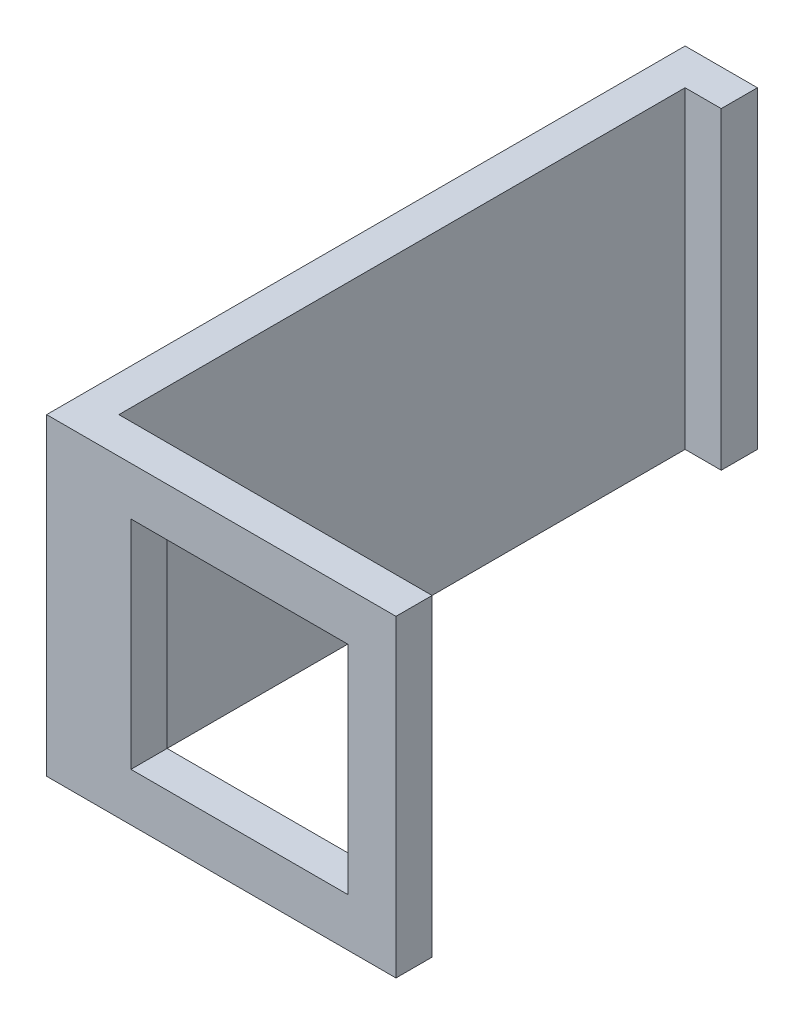
from build123d import *

# Parameters (mm, degrees)
SKETCH1_W           = 14.5
SKETCH1_H           = 13
SKETCH1_W_2         = 9
SKETCH1_H_2         = 9
BOSS_EXTRUDE1_DEPTH = 1.5
SKETCH2_W           = 1.5
SKETCH2_H           = 13
BOSS_EXTRUDE2_DEPTH = 25
SKETCH3_W           = 1.5
SKETCH3_H           = 13
BOSS_EXTRUDE3_DEPTH = 1.5


with BuildPart() as part:
    # Sketch1 → Boss-Extrude1 (new body)
    with BuildSketch(Plane.XY):
        Rectangle(SKETCH1_W, SKETCH1_H)
        with Locations((0.75, 0)):
            Rectangle(SKETCH1_W_2, SKETCH1_H_2, mode=Mode.SUBTRACT)
    extrude(amount=BOSS_EXTRUDE1_DEPTH)

    # Sketch2 → Boss-Extrude2 (add)
    with BuildSketch(Plane(origin=(0, 0, 0), x_dir=(-1, 0, 0), z_dir=(0, 0, -1))):
        with Locations((6.5, 0)):
            Rectangle(SKETCH2_W, SKETCH2_H)
    extrude(amount=BOSS_EXTRUDE2_DEPTH)

    # Sketch3 → Boss-Extrude3 (add)
    with BuildSketch(Plane(origin=(-5.75, 0, 0), x_dir=(0, 0, -1), z_dir=(1, 0, 0))):
        with Locations((24.25, 0)):
            Rectangle(SKETCH3_W, SKETCH3_H)
    extrude(amount=BOSS_EXTRUDE3_DEPTH)


solid = part.part
